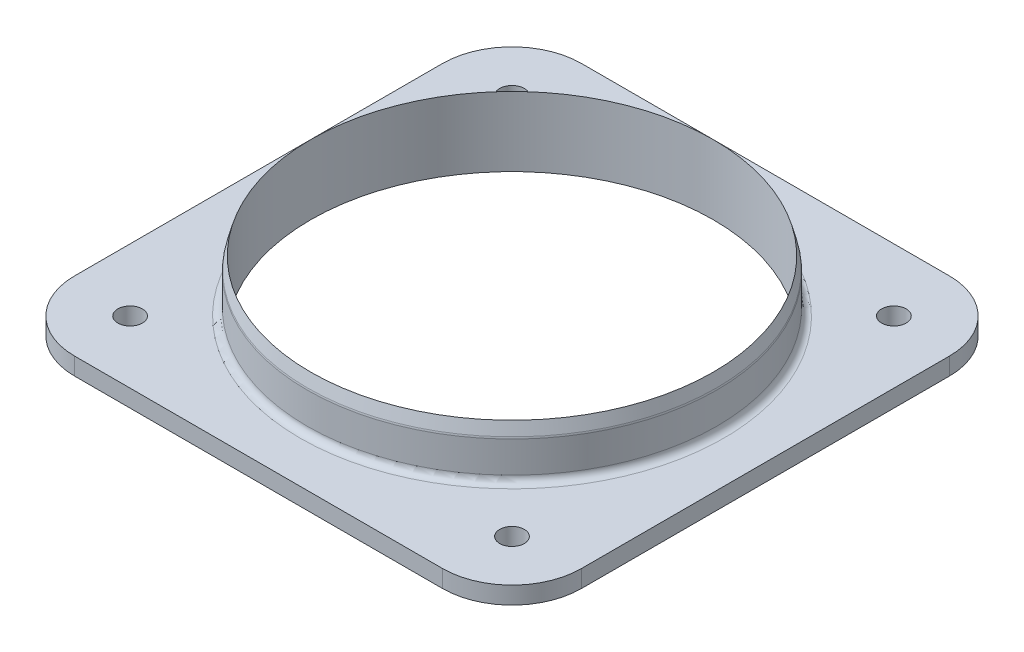
from build123d import *

# Parameters (mm, degrees)
SKETCH1_W           = 92.71
SKETCH1_H           = 92.71
SKETCH1_R           = 36.83
BOSS_EXTRUDE1_DEPTH = 3.175
SKETCH2_R           = 2.25
CUT_EXTRUDE1_DEPTH  = 4.175
CIRPATTERN1_COUNT   = 4
FILLET1_R           = 12.7
FILLET2_R           = 1.27


with BuildPart() as part:
    # Sketch1 → Boss-Extrude1 (new body)
    with BuildSketch(Plane(origin=(0, 0, 0), x_dir=(1, 0, 0), z_dir=(0, 1, 0))):
        Rectangle(SKETCH1_W, SKETCH1_H)
        Circle(SKETCH1_R, mode=Mode.SUBTRACT)
    extrude(amount=BOSS_EXTRUDE1_DEPTH)

    # Sketch2 → Cut-Extrude1 (cut, through all)
    with BuildSketch(Plane(origin=(0, 3.175, 0), x_dir=(1, 0, 0), z_dir=(0, 1, 0))):
        with Locations((-34.925, 34.925)):
            Circle(SKETCH2_R)
    cut_extrude1 = extrude(amount=-CUT_EXTRUDE1_DEPTH, mode=Mode.SUBTRACT)

    # CirPattern1: Cut-Extrude1 ×4 about axis
    cirpattern1_axis = Axis((0, 0, 0), (0, 1, 0))
    for i in range(1, CIRPATTERN1_COUNT):
        add(cut_extrude1.rotate(cirpattern1_axis, i * 360 / CIRPATTERN1_COUNT), mode=Mode.SUBTRACT)

    # Fillet1
    fillet1_edges = [part.edges().sort_by_distance(p)[0] for p in [
        (-46.355, 1.5875, -46.355),
        (46.355, 1.5875, -46.355),
        (46.355, 1.5875, 46.355),
        (-46.355, 1.5875, 46.355),
    ]]
    fillet(fillet1_edges, radius=FILLET1_R)

    # Sketch4 → Revolve1 (revolve)
    with BuildSketch(Plane.XY):
        Polygon((36.83, 12.7), (36.83, 3.175), (37.465, 3.175), (37.465, 10.330147737), align=None)
    revolve(axis=Axis((0, -1000, 0), (0, 1, 0)))

    # Fillet2
    fillet2_edges = [part.edges().sort_by_distance(p)[0] for p in [
        (-37.465, 3.175, 0),
        (-37.465, 10.330147737, 0),
    ]]
    fillet(fillet2_edges, radius=FILLET2_R)


solid = part.part
